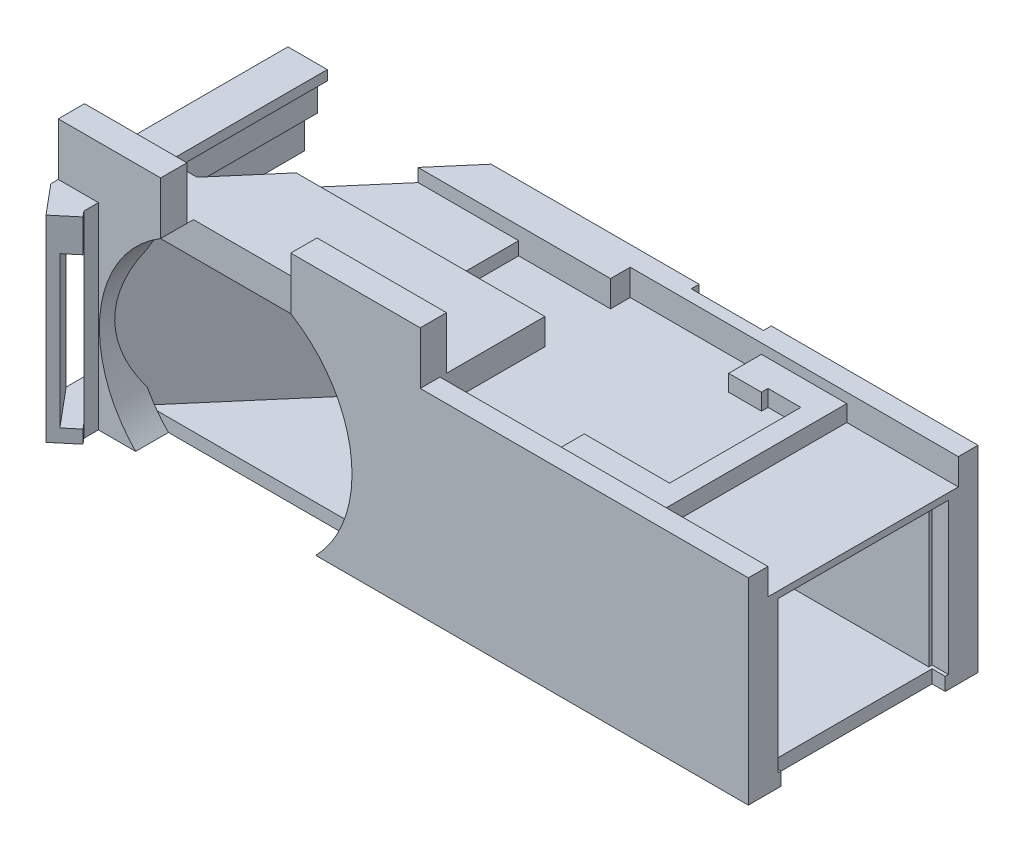
from build123d import *

# Parameters (mm, degrees)
BOSS_EXTRUDE3_DEPTH       = 30
SKETCH6_W                 = 25
SKETCH6_H                 = 23
CUT_EXTRUDE1_DEPTH        = 86
SKETCH7_W                 = 25
SKETCH7_H                 = 5
CUT_EXTRUDE2_DEPTH        = 7.5
SKETCH8_W                 = 25
SKETCH8_H                 = 2
CUT_EXTRUDE3_DEPTH        = 1
SKETCH9_R                 = 19.25
CUT_EXTRUDE4_DEPTH        = 5
BOSS_EXTRUDE4_DEPTH       = 30
SKETCH10_W                = 1.856561782
SKETCH10_H                = 30
BOSS_EXTRUDE5_DEPTH       = 3
BOSS_EXTRUDE6_DEPTH       = 30
SKETCH11_W                = 2.5
SKETCH11_H                = 23
CUT_EXTRUDE5_DEPTH        = 34.579503854
SKETCH12_W                = 29.135235428
SKETCH12_H                = 25
CUT_EXTRUDE6_DEPTH        = 3.5
SKETCH13_W                = 19.135235428
SKETCH13_H                = 5
CUT_EXTRUDE7_DEPTH        = 3.5
SKETCH14_W                = 29.135235428
SKETCH14_H                = 4
BOSS_EXTRUDE7_DEPTH       = 2
SKETCH16_W                = 29.135235428
SKETCH16_H                = 1.5
BOSS_EXTRUDE8_DEPTH       = 2
SKETCH17_W                = 2.551467674
SKETCH17_H                = 30
BOSS_EXTRUDE9_DEPTH       = 5
BOSS_EXTRUDE10_REACH      = 85.266
SKETCH18_W                = 29.135235428
SKETCH18_H                = 2.5
SKETCH19_W                = 2.48850009
SKETCH19_H                = 23
BOSS_EXTRUDE11_DEPTH      = 2
CUT_EXTRUDE8_START        = -2.4885
SKETCH20_W                = 2
SKETCH20_H                = 23
CUT_EXTRUDE8_DEPTH        = 21.736568
BOSS_EXTRUDE12_REACH      = 82.714
SKETCH21_W                = 2.023287715
SKETCH21_H                = 27.5
SKETCH22_W                = 35
SKETCH22_H                = 30
BOSS_EXTRUDE13_DEPTH      = 15.9
BOSS_EXTRUDE13_DEPTH_BACK = 7.5
SKETCH23_W                = 25
SKETCH23_H                = 23
CUT_EXTRUDE9_DEPTH        = 24.4
SKETCH24_W                = 25
SKETCH24_H                = 5
CUT_EXTRUDE10_DEPTH       = 2
SKETCH25_W                = 50
SKETCH25_H                = 29
CUT_EXTRUDE11_DEPTH       = 4
SKETCH26_W                = 3
SKETCH26_H                = 29
BOSS_EXTRUDE14_DEPTH      = 2.5
SKETCH27_W                = 5
SKETCH27_H                = 5
BOSS_EXTRUDE15_DEPTH      = 2.5
BOSS_EXTRUDE16_REACH      = 27
SKETCH28_W                = 4
SKETCH28_H                = 2.5
SKETCH29_W                = 13
SKETCH29_H                = 5
BOSS_EXTRUDE17_DEPTH      = 2.5
SKETCH30_W                = 10
SKETCH30_H                = 4
CUT_EXTRUDE12_DEPTH       = 14
CUT_EXTRUDE13_REACH       = 43.166
SKETCH31_W                = 10
SKETCH31_H                = 2
SKETCH32_W                = 2
SKETCH32_H                = 25
CUT_EXTRUDE14_DEPTH       = 27
SKETCH33_W                = 19.734733993
SKETCH33_H                = 4
BOSS_EXTRUDE18_DEPTH      = 8
SKETCH34_W                = 15.60048738
SKETCH34_H                = 4
BOSS_EXTRUDE19_DEPTH      = 8
SKETCH35_W                = 26
SKETCH35_H                = 23
CUT_EXTRUDE15_DEPTH       = 2.5
SKETCH36_W                = 25
SKETCH36_H                = 1
BOSS_EXTRUDE20_DEPTH      = 2
SKETCH39_W                = 1.5
SKETCH39_H                = 1
CUT_EXTRUDE16_DEPTH       = 29.135235
SKETCH42_W                = 11
SKETCH42_H                = 2
CUT_EXTRUDE17_DEPTH       = 1.2


with BuildPart() as part:
    # Sketch2 → Boss-Extrude3 (new body)
    with BuildSketch(Plane(origin=(0, 0, 0), x_dir=(1, 0, 0), z_dir=(0, 1, 0))):
        Polygon((-105.912162162, 13.018018018), (-20.912162162, 13.018018018), (-20.912162162, 48.018018018), (-75.912162162, 48.018018018), align=None)
    extrude(amount=BOSS_EXTRUDE3_DEPTH)

    # Sketch6 → Cut-Extrude1 (cut, through all)
    with BuildSketch(Plane(origin=(-20.912162162, 0, 0), x_dir=(0, 0, -1), z_dir=(1, 0, 0))):
        with Locations((30.518018018, 13.5)):
            Rectangle(SKETCH6_W, SKETCH6_H)
    extrude(amount=-CUT_EXTRUDE1_DEPTH, mode=Mode.SUBTRACT)

    # Sketch7 → Cut-Extrude2 (cut)
    with BuildSketch(Plane(origin=(-20.912162162, 0, 0), x_dir=(0, 0, -1), z_dir=(1, 0, 0))):
        with Locations((30.518018018, 27.5)):
            Rectangle(SKETCH7_W, SKETCH7_H)
    extrude(amount=-CUT_EXTRUDE2_DEPTH, mode=Mode.SUBTRACT)

    # Sketch8 → Cut-Extrude3 (cut)
    with BuildSketch(Plane(origin=(-20.912162162, 0, 0), x_dir=(0, 0, -1), z_dir=(1, 0, 0))):
        with Locations((30.518018018, 1)):
            Rectangle(SKETCH8_W, SKETCH8_H)
    extrude(amount=-CUT_EXTRUDE3_DEPTH, mode=Mode.SUBTRACT)

    # Sketch9 → Cut-Extrude4 (cut)
    with BuildSketch(Plane.XY.offset(-13.018018018)):
        with Locations((-84.662162162, 13.5)):
            Circle(SKETCH9_R)
    extrude(amount=-CUT_EXTRUDE4_DEPTH, mode=Mode.SUBTRACT)

    # Sketch3 → Boss-Extrude4 (add)
    with BuildSketch(Plane(origin=(0, 0, 0), x_dir=(1, 0, 0), z_dir=(0, 1, 0))):
        Polygon((-106.412808957, 7.383361614), (-110.17791555, 11.88278259), (-79.204856611, 48.018018018), (-75.912162162, 48.018018018), (-105.912162162, 13.018018018), (-103.345157358, 9.950366419), align=None)
    extrude(amount=BOSS_EXTRUDE4_DEPTH)

    # Sketch10 → Boss-Extrude5 (add)
    with BuildSketch(Plane.XY.offset(-13.018018018)):
        with Locations((-104.983881271, 15)):
            Rectangle(SKETCH10_W, SKETCH10_H)
    extrude(amount=BOSS_EXTRUDE5_DEPTH)

    # Sketch4 → Boss-Extrude6 (add)
    with BuildSketch(Plane(origin=(0, 0, 0), x_dir=(1, 0, 0), z_dir=(0, 1, 0))):
        Polygon((-110.17791555, 11.88278259), (-110.17791555, 48.018018018), (-104.17791555, 48.018018018), (-104.17791555, 18.88278259), align=None)
    extrude(amount=BOSS_EXTRUDE6_DEPTH)

    # Sketch11 → Cut-Extrude5 (cut, through all)
    with BuildSketch(Plane(origin=(-47.459390138, 0, -56.715466139), x_dir=(0.7669129, 0, -0.641751201), z_dir=(0.641751201, 0, 0.7669129))):
        with Locations((-74.121074711, 13.5)):
            Rectangle(SKETCH11_W, SKETCH11_H)
    extrude(amount=-CUT_EXTRUDE5_DEPTH, mode=Mode.SUBTRACT)

    # Sketch12 → Cut-Extrude6 (cut)
    with BuildSketch(Plane(origin=(-104.17791555, 0, 0), x_dir=(0, 0, -1), z_dir=(1, 0, 0))):
        with Locations((33.450400304, 15)):
            Rectangle(SKETCH12_W, SKETCH12_H)
    extrude(amount=-CUT_EXTRUDE6_DEPTH, mode=Mode.SUBTRACT)

    # Sketch13 → Cut-Extrude7 (cut, through all)
    with BuildSketch(Plane(origin=(-107.67791555, 0, 0), x_dir=(0, 0, -1), z_dir=(1, 0, 0))):
        with Locations((38.450400304, 15)):
            Rectangle(SKETCH13_W, SKETCH13_H)
    extrude(amount=-CUT_EXTRUDE7_DEPTH, mode=Mode.SUBTRACT)

    # Sketch14 → Boss-Extrude7 (add)
    with BuildSketch(Plane(origin=(-107.67791555, 0, 0), x_dir=(0, 0, -1), z_dir=(1, 0, 0))):
        with Locations((33.450400304, 25.5)):
            Rectangle(SKETCH14_W, SKETCH14_H)
    extrude(amount=BOSS_EXTRUDE7_DEPTH)

    # Sketch16 → Boss-Extrude8 (add)
    with BuildSketch(Plane(origin=(-107.67791555, 0, 0), x_dir=(0, 0, -1), z_dir=(1, 0, 0))):
        with Locations((33.450400304, 3.25)):
            Rectangle(SKETCH16_W, SKETCH16_H)
    extrude(amount=BOSS_EXTRUDE8_DEPTH)

    # Sketch17 → Boss-Extrude9 (add)
    with BuildSketch(Plane(origin=(0, 0, -18.88278259), x_dir=(-1, 0, 0), z_dir=(0, 0, -1))):
        with Locations((102.902181713, 15)):
            Rectangle(SKETCH17_W, SKETCH17_H)
    extrude(amount=BOSS_EXTRUDE9_DEPTH)

    # Boss-Extrude10: up to this face of the body (flat: up to its plane)
    boss_extrude10_end = Plane(part.part.faces().sort_by_distance((-90.415652244, 15, -34.938756447))[0])
    # Sketch18 → Boss-Extrude10 (add, up to the picked face)
    with BuildSketch(Plane(origin=(-104.17791555, 0, 0), x_dir=(0, 0, -1), z_dir=(1, 0, 0)), mode=Mode.PRIVATE) as boss_extrude10_sk1:
        with Locations((33.450400304, 1.25)):
            Rectangle(SKETCH18_W, SKETCH18_H)
    boss_extrude10_tool1 = split(extrude(boss_extrude10_sk1.sketch, amount=BOSS_EXTRUDE10_REACH, mode=Mode.PRIVATE), bisect_by=boss_extrude10_end, keep=Keep.BOTH, mode=Mode.PRIVATE)
    add(boss_extrude10_tool1.solids().sort_by_distance((-104.177916, 1.25, -33.4504))[0])

    # Sketch19 → Boss-Extrude11 (add)
    with BuildSketch(Plane(origin=(-67.487678855, 0, -57.846581876), x_dir=(0.650791373, 0, -0.759256602), z_dir=(0.759256602, 0, 0.650791373))):
        with Locations((-31.723015124, 13.5)):
            Rectangle(SKETCH19_W, SKETCH19_H)
    extrude(amount=BOSS_EXTRUDE11_DEPTH)

    # Sketch20 → Cut-Extrude8 (cut)
    with BuildSketch(Plane(origin=(-19.835317387, 0, 23.141203618), x_dir=(-0.759256602, 0, -0.650791373), z_dir=(0.650791373, 0, -0.759256602)).offset(CUT_EXTRUDE8_START)):
        with Locations((87.886522218, 13.5)):
            Rectangle(SKETCH20_W, SKETCH20_H)
    extrude(amount=CUT_EXTRUDE8_DEPTH, mode=Mode.SUBTRACT)

    # Boss-Extrude12: up to this face of the body (flat: up to its plane)
    boss_extrude12_end = Plane(part.part.faces().sort_by_distance((-90.415652244, 16.25, -34.938756447))[0])
    # Sketch21 → Boss-Extrude12 (add, up to the picked face)
    with BuildSketch(Plane(origin=(-101.626447876, 0, 0), x_dir=(0, 0, -1), z_dir=(1, 0, 0)), mode=Mode.PRIVATE) as boss_extrude12_sk1:
        with Locations((22.871138733, 16.25)):
            Rectangle(SKETCH21_W, SKETCH21_H)
    boss_extrude12_tool1 = split(extrude(boss_extrude12_sk1.sketch, amount=BOSS_EXTRUDE12_REACH, mode=Mode.PRIVATE), bisect_by=boss_extrude12_end, keep=Keep.BOTH, mode=Mode.PRIVATE)
    add(boss_extrude12_tool1.solids().sort_by_distance((-101.626448, 16.25, -22.871139))[0])

    # Sketch22 → Boss-Extrude13 (add, two sides)
    with BuildSketch(Plane(origin=(-20.912162162, 0, 0), x_dir=(0, 0, -1), z_dir=(1, 0, 0))) as boss_extrude13_sk:
        with Locations((30.518018018, 15)):
            Rectangle(SKETCH22_W, SKETCH22_H)
    extrude(amount=BOSS_EXTRUDE13_DEPTH)
    extrude(boss_extrude13_sk.sketch, amount=-BOSS_EXTRUDE13_DEPTH_BACK)

    # Sketch23 → Cut-Extrude9 (cut, through all)
    with BuildSketch(Plane.ZY.offset(28.412162162)):
        with Locations((-30.518018018, 13.5)):
            Rectangle(SKETCH23_W, SKETCH23_H)
    extrude(amount=-CUT_EXTRUDE9_DEPTH, mode=Mode.SUBTRACT)

    # Sketch24 → Cut-Extrude10 (cut)
    with BuildSketch(Plane(origin=(-5.012162162, 0, 0), x_dir=(0, 0, -1), z_dir=(1, 0, 0))):
        with Locations((30.518018018, 27.5)):
            Rectangle(SKETCH24_W, SKETCH24_H)
    extrude(amount=-CUT_EXTRUDE10_DEPTH, mode=Mode.SUBTRACT)

    # Sketch25 → Cut-Extrude11 (cut)
    with BuildSketch(Plane(origin=(0, 30, 0), x_dir=(1, 0, 0), z_dir=(0, 1, 0))):
        with Locations((-30.012162162, 30.518018018)):
            Rectangle(SKETCH25_W, SKETCH25_H)
    extrude(amount=-CUT_EXTRUDE11_DEPTH, mode=Mode.SUBTRACT)

    # Sketch26 → Boss-Extrude14 (add)
    with BuildSketch(Plane(origin=(0, 26, 0), x_dir=(1, 0, 0), z_dir=(0, 1, 0))):
        with Locations((-23.512162162, 30.518018018)):
            Rectangle(SKETCH26_W, SKETCH26_H)
    extrude(amount=BOSS_EXTRUDE14_DEPTH)

    # Sketch27 → Boss-Extrude15 (add)
    with BuildSketch(Plane(origin=(0, 26, 0), x_dir=(1, 0, 0), z_dir=(0, 1, 0))):
        with Locations((-32.512162162, 42.518018018)):
            Rectangle(SKETCH27_W, SKETCH27_H)
    extrude(amount=BOSS_EXTRUDE15_DEPTH)

    # Sketch28 → Boss-Extrude16 (add, up to next)
    with BuildSketch(Plane(origin=(-30.012162162, 0, 0), x_dir=(0, 0, -1), z_dir=(1, 0, 0)), mode=Mode.PRIVATE) as boss_extrude16_sk1:
        with Locations((43.018018018, 27.25)):
            Rectangle(SKETCH28_W, SKETCH28_H)
    boss_extrude16_tool1 = extrude(boss_extrude16_sk1.sketch, amount=BOSS_EXTRUDE16_REACH, mode=Mode.PRIVATE) - part.part
    add(boss_extrude16_tool1.solids().sort_by_distance((-30.012162, 27.25, -43.018018))[0])

    # Sketch29 → Boss-Extrude17 (add)
    with BuildSketch(Plane(origin=(0, 26, 0), x_dir=(1, 0, 0), z_dir=(0, 1, 0))):
        with Locations((-31.512162162, 18.518018018)):
            Rectangle(SKETCH29_W, SKETCH29_H)
    extrude(amount=BOSS_EXTRUDE17_DEPTH)

    # Sketch30 → Cut-Extrude12 (cut)
    with BuildSketch(Plane(origin=(-55.012162162, 0, 0), x_dir=(0, 0, -1), z_dir=(1, 0, 0))):
        with Locations((37.018018018, 28)):
            Rectangle(SKETCH30_W, SKETCH30_H)
    extrude(amount=-CUT_EXTRUDE12_DEPTH, mode=Mode.SUBTRACT)

    # Sketch31 → Cut-Extrude13 (cut, up to next)
    with BuildSketch(Plane(origin=(-69.012162162, 0, 0), x_dir=(0, 0, -1), z_dir=(1, 0, 0)), mode=Mode.PRIVATE) as cut_extrude13_sk1:
        with Locations((37.018018018, 29)):
            Rectangle(SKETCH31_W, SKETCH31_H)
    cut_extrude13_tool1 = extrude(cut_extrude13_sk1.sketch, amount=-CUT_EXTRUDE13_REACH, mode=Mode.PRIVATE) & part.part
    add(cut_extrude13_tool1.solids().sort_by_distance((-69.012162, 29, -37.018018))[0], mode=Mode.SUBTRACT)

    # Sketch32 → Cut-Extrude14 (cut, through all)
    with BuildSketch(Plane(origin=(0, 26, 0), x_dir=(1, 0, 0), z_dir=(0, 1, 0))):
        with Locations((-6.012162162, 30.518018018)):
            Rectangle(SKETCH32_W, SKETCH32_H)
    extrude(amount=-CUT_EXTRUDE14_DEPTH, mode=Mode.SUBTRACT)

    # Sketch33 → Boss-Extrude18 (add)
    with BuildSketch(Plane(origin=(0, 30, 0), x_dir=(1, 0, 0), z_dir=(0, 1, 0))):
        with Locations((-64.879529159, 15.018018018)):
            Rectangle(SKETCH33_W, SKETCH33_H)
    extrude(amount=BOSS_EXTRUDE18_DEPTH)

    # Sketch34 → Boss-Extrude19 (add)
    with BuildSketch(Plane(origin=(0, 30, 0), x_dir=(1, 0, 0), z_dir=(0, 1, 0))):
        with Locations((-102.37767186, 15.018018018)):
            Rectangle(SKETCH34_W, SKETCH34_H)
    extrude(amount=BOSS_EXTRUDE19_DEPTH)

    # Sketch35 → Cut-Extrude15 (cut)
    with BuildSketch(Plane(origin=(-5.012162162, 0, 0), x_dir=(0, 0, -1), z_dir=(1, 0, 0))):
        with Locations((30.518018018, 13.5)):
            Rectangle(SKETCH35_W, SKETCH35_H)
    extrude(amount=-CUT_EXTRUDE15_DEPTH, mode=Mode.SUBTRACT)

    # Sketch36 → Boss-Extrude20 (add)
    with BuildSketch(Plane(origin=(-7.012162162, 0, 0), x_dir=(0, 0, -1), z_dir=(1, 0, 0))):
        with Locations((30.518018018, 25.5)):
            Rectangle(SKETCH36_W, SKETCH36_H)
    extrude(amount=BOSS_EXTRUDE20_DEPTH)

    # Sketch39 → Cut-Extrude16 (cut)
    with BuildSketch(Plane(origin=(0, 0, -48.018018018), x_dir=(-1, 0, 0), z_dir=(0, 0, -1))):
        with Locations((104.92791555, 28)):
            Rectangle(SKETCH39_W, SKETCH39_H)
    extrude(amount=-CUT_EXTRUDE16_DEPTH, mode=Mode.SUBTRACT)

    # Sketch42 → Cut-Extrude17 (cut)
    with BuildSketch(Plane(origin=(0, 0, -48.018018018), x_dir=(-1, 0, 0), z_dir=(0, 0, -1))):
        with Locations((42.012162162, 29)):
            Rectangle(SKETCH42_W, SKETCH42_H)
    extrude(amount=-CUT_EXTRUDE17_DEPTH, mode=Mode.SUBTRACT)


solid = part.part
